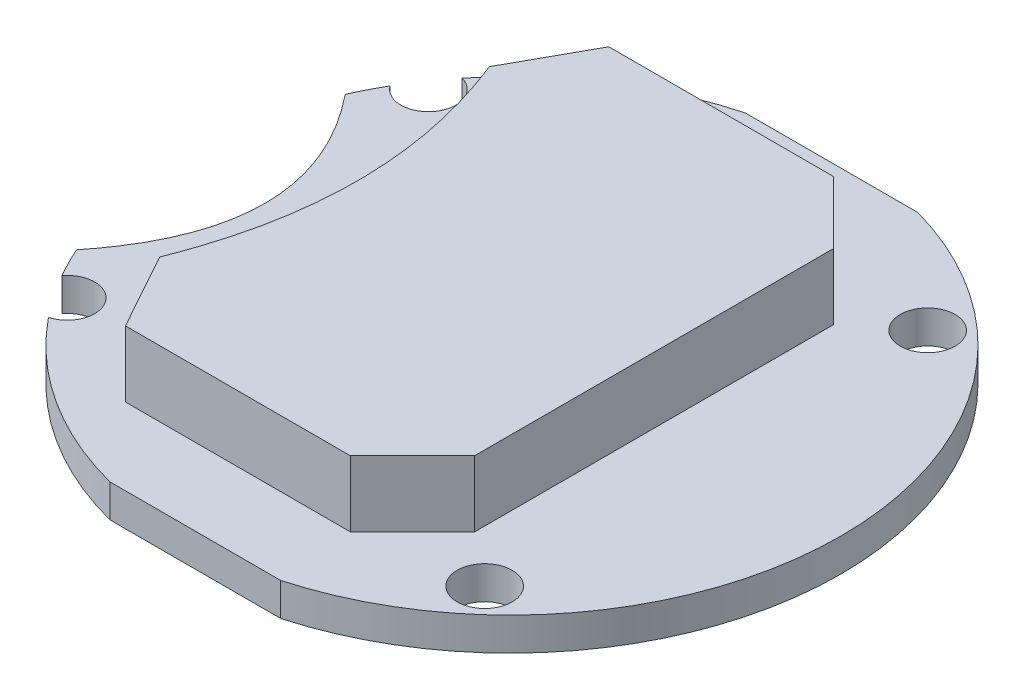
from build123d import *

# Parameters (mm, degrees)
EXTRUDE_1_DEPTH     = 1.5
EXTRUDE_2_DEPTH     = 3
SKETCH_5_R          = 1.25
CUT_EXTRUDE_2_DEPTH = 2.5000001
CUT_EXTRUDE_3_DEPTH = 2.5000001


with BuildPart() as part:
    # Эскиз1 → Бобышка-Вытянуть1 (new body)
    with BuildSketch(Plane(origin=(0, 0, 0), x_dir=(1, 0, 0), z_dir=(0, 1, 0))):
        with BuildLine():
            Line((5, 14.5), (-5, 14.5))
            ThreePointArc((-5, 14.5), (-9.453000697, 12.420644275), (-13, 9.018919508))
            Line((-13, 9.018919508), (-13, 6.5))
            add(Edge.make_bspline(
                [(-13, 6.5), (-7.441418368, 0), (-13, -6.5)],
                knots=[0, 0, 0, 1, 1, 1], degree=2))
            Line((-13, -6.5), (-13, -9.018919508))
            ThreePointArc((-13, -9.018919508), (-9.453000697, -12.420644275), (-5, -14.5))
            Line((-5, -14.5), (5, -14.5))
            ThreePointArc((5, -14.5), (15.997963501, 0), (5, 14.5))
        make_face()
    extrude(amount=EXTRUDE_1_DEPTH)

    # Эскиз3 → Бобышка-Вытянуть2 (add)
    with BuildSketch(Plane(origin=(0, 1.5, 0), x_dir=(1, 0, 0), z_dir=(0, 1, 0))):
        with BuildLine():
            Line((4.668952027, -11), (7.497379152, -8.171572875))
            Line((7.497379152, -8.171572875), (7.497379152, 8.171572875))
            Line((7.497379152, 8.171572875), (4.668952027, 11))
            Line((4.668952027, 11), (-5.566129175, 11))
            Line((-5.566129175, 11), (-7.502620848, 7.5))
            add(Edge.make_bspline(
                [(-7.502620848, 7.5), (-4.502620848, 0), (-7.502620848, -7.5)],
                knots=[0, 0, 0, 1, 1, 1], degree=2))
            Line((-7.502620848, -7.5), (-5.566129175, -11))
            Line((-5.566129175, -11), (4.668952027, -11))
        make_face()
    extrude(amount=EXTRUDE_2_DEPTH)

    # Эскиз5 → Вырез-Вытянуть2 (cut, through all)
    with BuildSketch(Plane(origin=(0, 1.5, 0), x_dir=(1, 0, 0), z_dir=(0, 1, 0))):
        with Locations((9.863113254, 10.081034519)):
            Circle(SKETCH_5_R)
        with Locations((-10.997789514, 8.218757238)):
            Circle(SKETCH_5_R)
        with Locations((9.863113254, -10.081034519)):
            Circle(SKETCH_5_R)
        with Locations((-10.997789514, -8.218757238)):
            Circle(SKETCH_5_R)
    extrude(amount=-CUT_EXTRUDE_2_DEPTH, mode=Mode.SUBTRACT)

    # Эскиз7 → Вырез-Вытянуть3 (cut, through all)
    with BuildSketch(Plane(origin=(0, 1.5, 0), x_dir=(1, 0, 0), z_dir=(0, 1, 0))):
        with BuildLine():
            Line((-13, 9.018919508), (-13, 6.5))
            Line((-13, 6.5), (-12.715649732, 6.077566297))
            ThreePointArc((-12.715649732, 6.077566297), (-8.737112762, 11.411761045), (-2.842609373, 14.5))
            Line((-2.842609373, 14.5), (-5, 14.5))
            ThreePointArc((-5, 14.5), (-9.453000697, 12.420644275), (-13, 9.018919508))
        make_face()
        with BuildLine():
            Line((-13, -6.5), (-13, -9.018919508))
            ThreePointArc((-13, -9.018919508), (-9.453000697, -12.420644275), (-5, -14.5))
            Line((-5, -14.5), (-2.763931787, -14.5))
            ThreePointArc((-2.763931787, -14.5), (-8.693434445, -11.422725682), (-12.695530111, -6.07372117))
            Line((-12.695530111, -6.07372117), (-13, -6.5))
        make_face()
    extrude(amount=-CUT_EXTRUDE_3_DEPTH, mode=Mode.SUBTRACT)


solid = part.part
